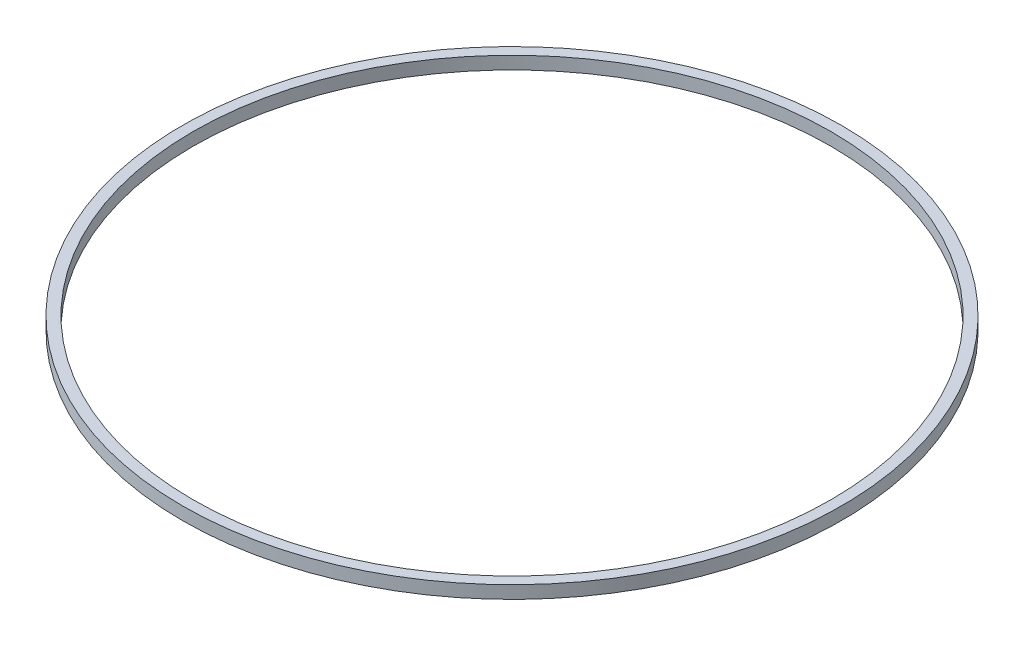
from build123d import *

# Parameters (mm, degrees)
SKETCH1_R           = 77.5
SKETCH1_R_2         = 75
BOSS_EXTRUDE1_DEPTH = 3


with BuildPart() as part:
    # Sketch1 → Boss-Extrude1 (new body)
    with BuildSketch(Plane(origin=(0, 0, 0), x_dir=(1, 0, 0), z_dir=(0, 1, 0))):
        Circle(SKETCH1_R)
        Circle(SKETCH1_R_2, mode=Mode.SUBTRACT)
    extrude(amount=BOSS_EXTRUDE1_DEPTH)


solid = part.part
